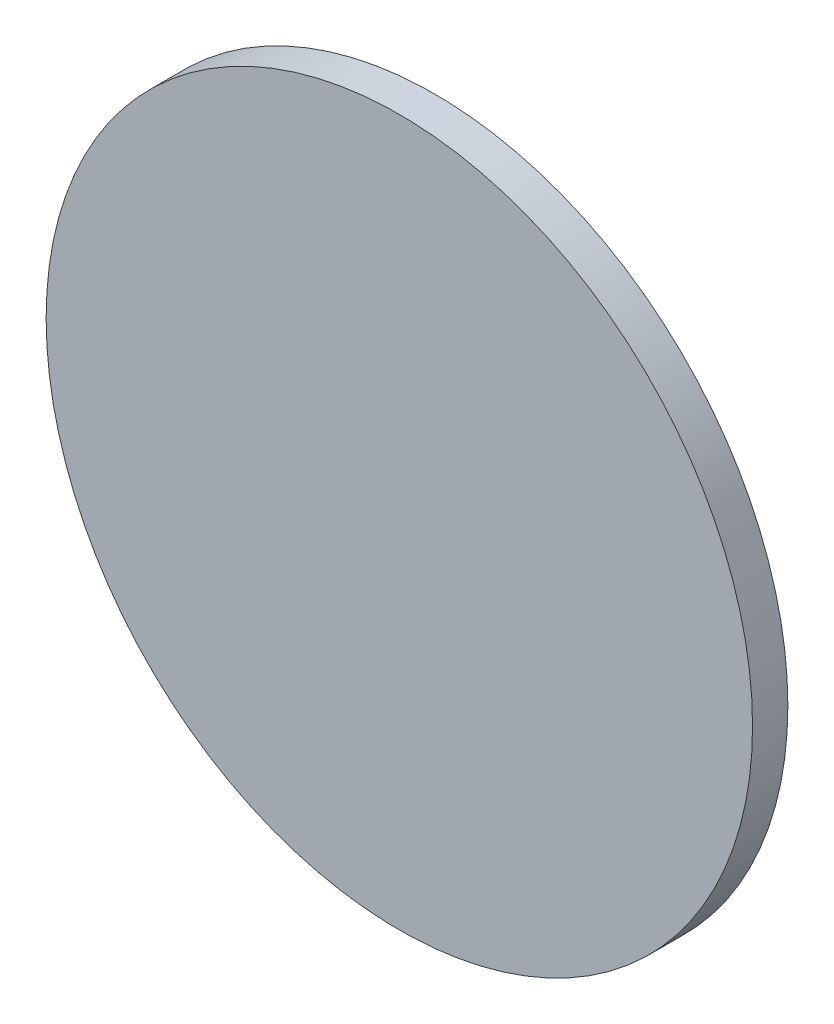
from build123d import *

# Parameters (mm, degrees)
SKETCH1_R           = 100
BOSS_EXTRUDE1_DEPTH = 10


with BuildPart() as part:
    # Sketch1 → Boss-Extrude1 (new body)
    with BuildSketch(Plane.XY):
        Circle(SKETCH1_R)
    extrude(amount=BOSS_EXTRUDE1_DEPTH)


solid = part.part
